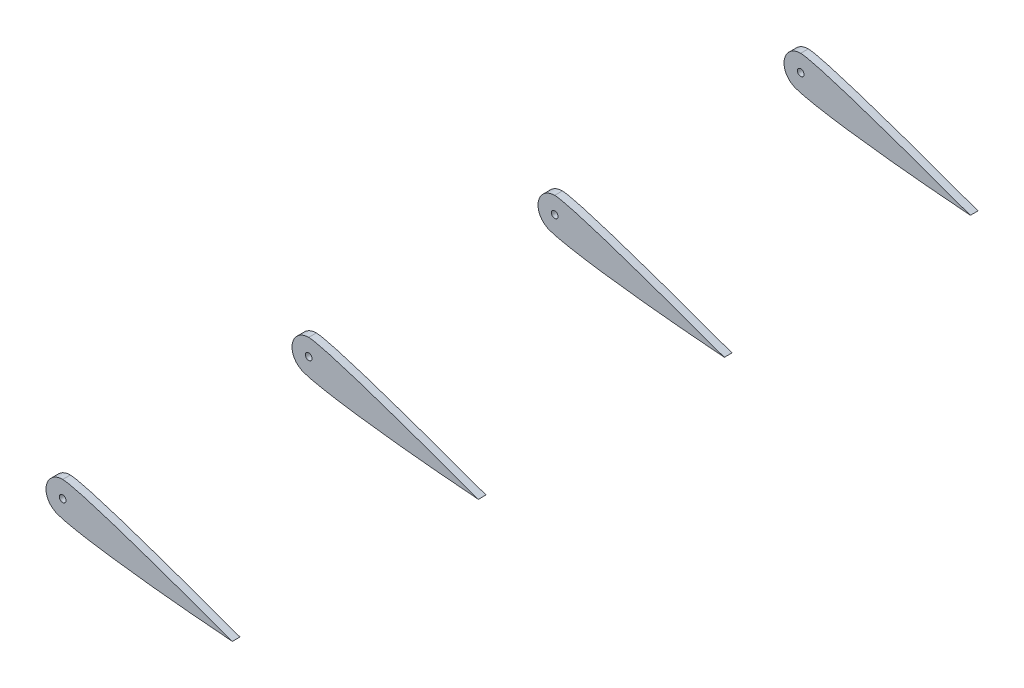
from build123d import *

# Parameters (mm, degrees)
SKETCH2_R           = 1
BOSS_EXTRUDE4_DEPTH = 2.286
SKETCH9_R           = 1
BOSS_EXTRUDE5_DEPTH = 2.286
SKETCH10_R          = 1
BOSS_EXTRUDE6_DEPTH = 2.286
SKETCH13_R          = 1
BOSS_EXTRUDE7_DEPTH = 2.286


with BuildPart() as part:
    # Sketch2 → Boss-Extrude4 (new body)
    with BuildSketch(Plane.XY):
        with BuildLine():
            ThreePointArc((0, 5), (-4.840543404, 1.252653008), (-2.425408502, -4.372344177))
            add(Edge.make_bspline(
                [(-2.425408502, -4.372344177), (-0.75384545, -5.811128073), (16.922119164, -8.962359502), (50.8, -11.610741386)],
                knots=[0, 0, 0, 0, 1, 1, 1, 1], degree=3))
            add(Edge.make_bspline(
                [(0, 5), (5.832463916, 4.850394407), (50.8, -11.610741386)],
                knots=[0, 0, 0, 1, 1, 1], degree=2))
        make_face()
        Circle(SKETCH2_R, mode=Mode.SUBTRACT)
    extrude(amount=BOSS_EXTRUDE4_DEPTH)


with BuildPart() as body_2:
    # Sketch9 → Boss-Extrude5 (new body)
    with BuildSketch(Plane.XY.offset(73.66)):
        with BuildLine():
            ThreePointArc((0, 5), (-4.840543404, 1.252653008), (-2.425408502, -4.372344177))
            add(Edge.make_bspline(
                [(-2.425408502, -4.372344177), (-0.75384545, -5.811128073), (16.922119164, -8.962359502), (50.8, -11.610741386)],
                knots=[0, 0, 0, 0, 1, 1, 1, 1], degree=3))
            add(Edge.make_bspline(
                [(0, 5), (5.832463916, 4.850394407), (50.8, -11.610741386)],
                knots=[0, 0, 0, 1, 1, 1], degree=2))
        make_face()
        Circle(SKETCH9_R, mode=Mode.SUBTRACT)
    extrude(amount=BOSS_EXTRUDE5_DEPTH)


with BuildPart() as body_3:
    # Sketch10 → Boss-Extrude6 (new body)
    with BuildSketch(Plane.XY.offset(147.32)):
        with BuildLine():
            ThreePointArc((0, 5), (-4.840543404, 1.252653008), (-2.425408502, -4.372344177))
            add(Edge.make_bspline(
                [(-2.425408502, -4.372344177), (-0.75384545, -5.811128073), (16.922119164, -8.962359502), (50.8, -11.610741386)],
                knots=[0, 0, 0, 0, 1, 1, 1, 1], degree=3))
            add(Edge.make_bspline(
                [(0, 5), (5.832463916, 4.850394407), (50.8, -11.610741386)],
                knots=[0, 0, 0, 1, 1, 1], degree=2))
        make_face()
        Circle(SKETCH10_R, mode=Mode.SUBTRACT)
    extrude(amount=BOSS_EXTRUDE6_DEPTH)


with BuildPart() as body_4:
    # Sketch13 → Boss-Extrude7 (new body)
    with BuildSketch(Plane.XY.offset(220.98)):
        with BuildLine():
            ThreePointArc((0, 5), (-4.840543404, 1.252653008), (-2.425408502, -4.372344177))
            add(Edge.make_bspline(
                [(-2.425408502, -4.372344177), (-0.75384545, -5.811128073), (16.922119164, -8.962359502), (50.8, -11.610741386)],
                knots=[0, 0, 0, 0, 1, 1, 1, 1], degree=3))
            add(Edge.make_bspline(
                [(0, 5), (5.832463916, 4.850394407), (50.8, -11.610741386)],
                knots=[0, 0, 0, 1, 1, 1], degree=2))
        make_face()
        Circle(SKETCH13_R, mode=Mode.SUBTRACT)
    extrude(amount=BOSS_EXTRUDE7_DEPTH)


solid = Compound([part.part, body_2.part, body_3.part, body_4.part])
